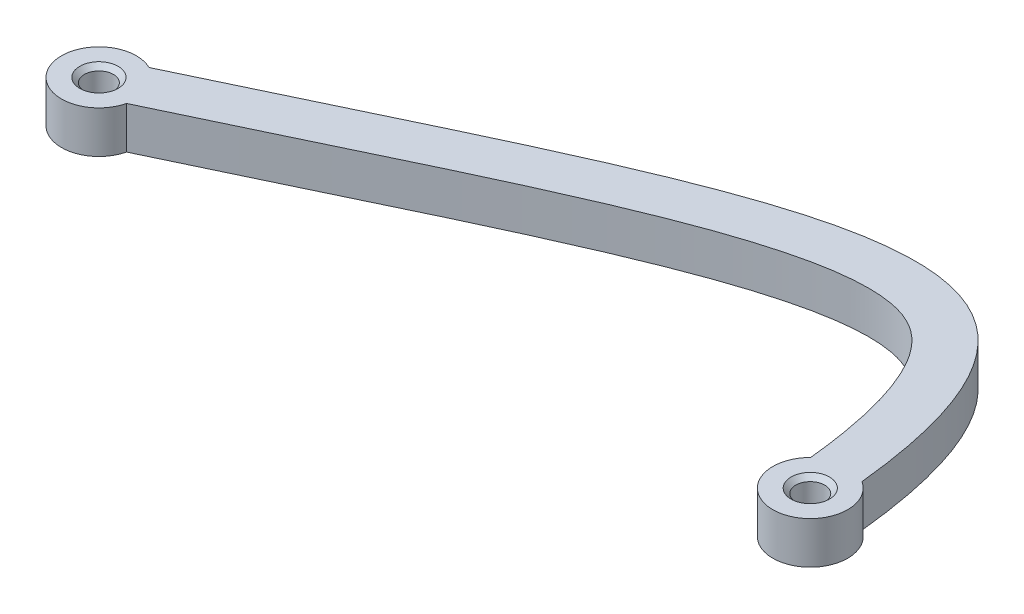
from build123d import *

# Parameters (mm, degrees)
SKETCH3_R           = 1.55
BOSS_EXTRUDE1_DEPTH = 2.25
CHAMFER1_SIZE       = 0.5


with BuildPart() as part:
    # Sketch3 → Boss-Extrude1 (new body, symmetric)
    with BuildSketch(Plane(origin=(0, 0, 0), x_dir=(1, 0, 0), z_dir=(0, 1, 0))):
        with BuildLine():
            ThreePointArc((-2.80821547, 2.84849537), (0.411852892, -3.978740654), (2.165210348, 3.363311485))
            add(Edge.make_bspline(
                [(-74.235072149, 3.589572353), (-27.485482272, 25.523814126), (-1.842755976, 42.082618466), (2.165210348, 3.363311485)],
                knots=[0, 0, 0, 0, 1, 1, 1, 1], degree=3))
            ThreePointArc((-74.235072149, 3.589572353), (-79.621229083, -1.699029113), (-72.111285757, -0.936964001))
            add(Edge.make_bspline(
                [(-72.111285757, -0.936964001), (-71.382108659, -0.594844491), (-69.917251853, 0.094667481), (-67.049234703, 1.45209838), (-63.539724816, 3.124374093), (-59.462435041, 5.076470765), (-54.201449811, 7.59587191), (-47.958388467, 10.563969303), (-41.009247812, 13.759956724), (-34.617613527, 16.513148974), (-26.871463459, 19.496190833), (-20.351407752, 21.288761702), (-15.316977929, 21.723706174), (-12.356142276, 21.425163203), (-10.144784364, 20.631187861), (-8.338210468, 19.350526304), (-6.611394971, 17.231248815), (-5.267852087, 14.452861921), (-4.332671494, 11.546431493), (-3.717026418, 9.021473164), (-3.285270796, 6.617744988), (-2.994980954, 4.531394989), (-2.865617891, 3.403036451), (-2.80821547, 2.84849537)],
                knots=[0, 0, 0, 0, 0.015625, 0.03125, 0.0625, 0.09375, 0.125, 0.1875, 0.25, 0.3125, 0.375, 0.5, 0.5625, 0.625, 0.6875, 0.75, 0.8125, 0.875, 0.90625, 0.9375, 0.96875, 0.984375, 1, 1, 1, 1], degree=3))
        make_face()
        with Locations((-76, 0)):
            Circle(SKETCH3_R, mode=Mode.SUBTRACT)
        Circle(SKETCH3_R, mode=Mode.SUBTRACT)
    extrude(amount=BOSS_EXTRUDE1_DEPTH, both=True)

    # Chamfer1
    chamfer1_edges = [part.edges().sort_by_distance(p)[0] for p in [
        (-77.55, -2.25, 0),
        (-1.55, -2.25, 0),
        (-77.55, 2.25, 0),
        (-1.55, 2.25, 0),
    ]]
    chamfer(chamfer1_edges, length=CHAMFER1_SIZE)


solid = part.part
